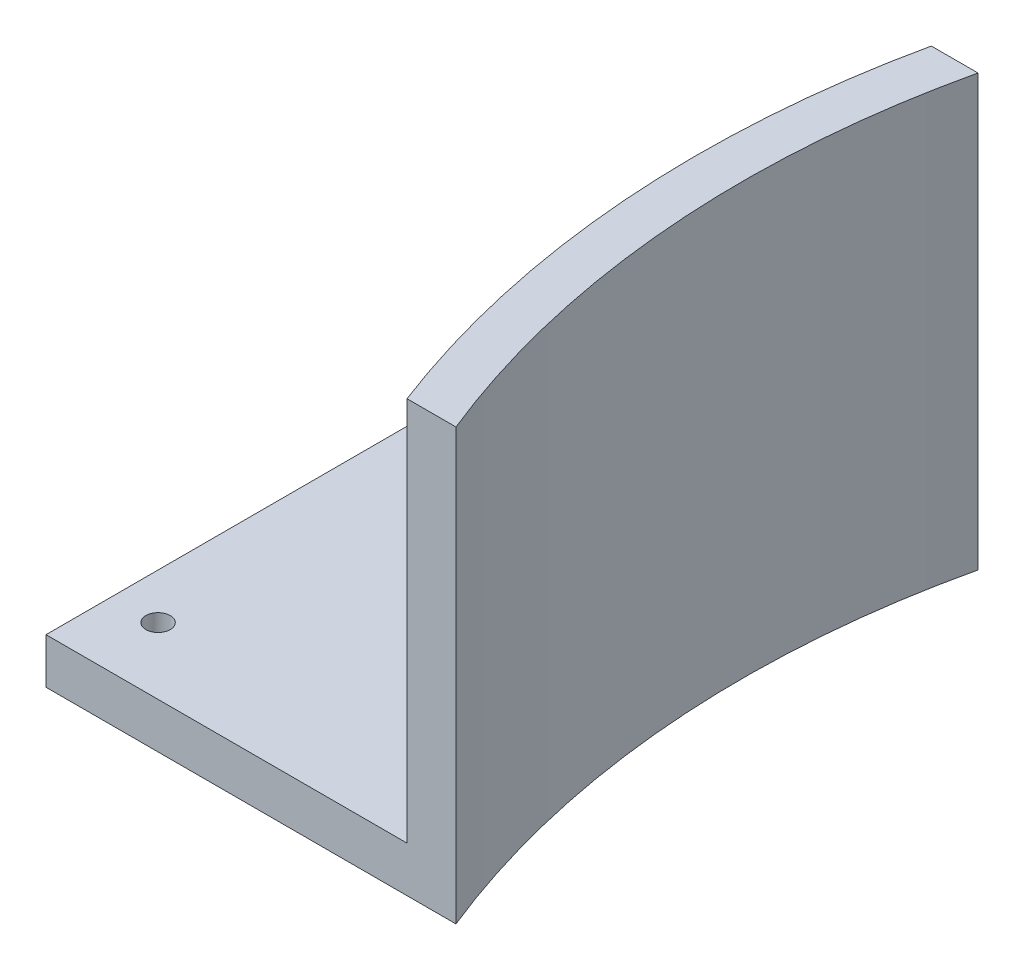
from build123d import *

# Parameters (mm, degrees)
BOSS_EXTRUDE1_DEPTH = 59.999999888
CUT_EXTRUDE1_START  = 60
CUT_EXTRUDE1_DEPTH  = 53.65
SKETCH4_R           = 1.700000029
CUT_EXTRUDE2_DEPTH  = 7.35


with BuildPart() as part:
    # Sketch1 → Boss-Extrude1 (new body)
    with BuildSketch(Plane(origin=(0, 0, 0), x_dir=(1, 0, 0), z_dir=(0, 1, 0))):
        with BuildLine():
            Line((50.8, 79.121), (0, 79.121))
            Line((0, 79.121), (0, 0))
            Line((0, 0), (57.15, 0))
            ThreePointArc((57.15, 0), (47.890801483, 39.072201564), (50.8, 79.121))
        make_face()
    extrude(amount=BOSS_EXTRUDE1_DEPTH)

    # Sketch3 → Cut-Extrude1 (cut)
    with BuildSketch(Plane(origin=(0, 0, 0), x_dir=(1, 0, 0), z_dir=(0, 1, 0)).offset(CUT_EXTRUDE1_START)):
        with BuildLine():
            Line((51.265506183, -2.386468628), (0, 0))
            Line((0, 0), (0, 79.121))
            Line((0, 79.121), (44.293451527, 79.121))
            ThreePointArc((44.293451527, 79.121), (41.621147879, 37.840489172), (51.265506183, -2.386468628))
        make_face()
    extrude(amount=-CUT_EXTRUDE1_DEPTH, mode=Mode.SUBTRACT)

    # Sketch4 → Cut-Extrude2 (cut, through all)
    with BuildSketch(Plane(origin=(0, 6.35, 0), x_dir=(1, 0, 0), z_dir=(0, 1, 0))):
        with Locations((6.35, 72.771)):
            Circle(SKETCH4_R)
        with Locations((25.4, 72.771)):
            Circle(SKETCH4_R)
        with Locations((6.35, 9.271)):
            Circle(SKETCH4_R)
    extrude(amount=-CUT_EXTRUDE2_DEPTH, mode=Mode.SUBTRACT)


solid = part.part
